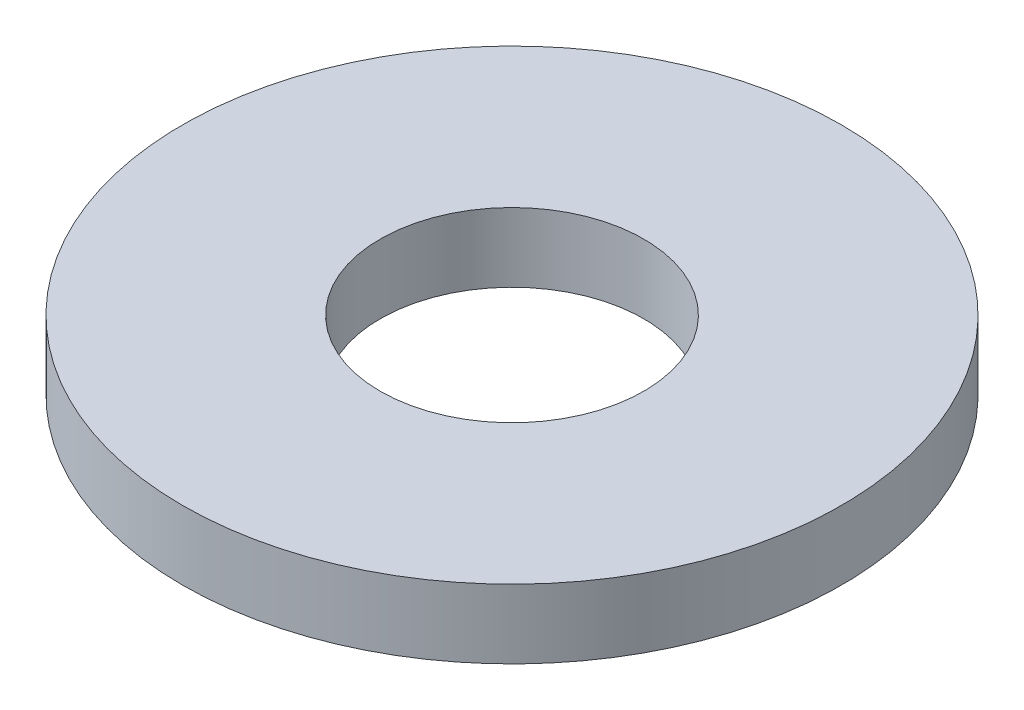
from build123d import *

# Parameters (mm, degrees)
SKETCH1_R           = 4.0005
BOSS_EXTRUDE1_DEPTH = 0.8382
SKETCH5_R           = 1.6002
CUT_EXTRUDE1_DEPTH  = 1.8382


with BuildPart() as part:
    # Sketch1 → Boss-Extrude1 (new body)
    with BuildSketch(Plane(origin=(0, 0, 0), x_dir=(1, 0, 0), z_dir=(0, 1, 0))):
        Circle(SKETCH1_R)
    extrude(amount=BOSS_EXTRUDE1_DEPTH)

    # Sketch5 → Cut-Extrude1 (cut, through all)
    with BuildSketch(Plane(origin=(0, 0.8382, 0), x_dir=(-1, 0, 0), z_dir=(0, 1, 0))):
        Circle(SKETCH5_R)
    extrude(amount=-CUT_EXTRUDE1_DEPTH, mode=Mode.SUBTRACT)


solid = part.part
